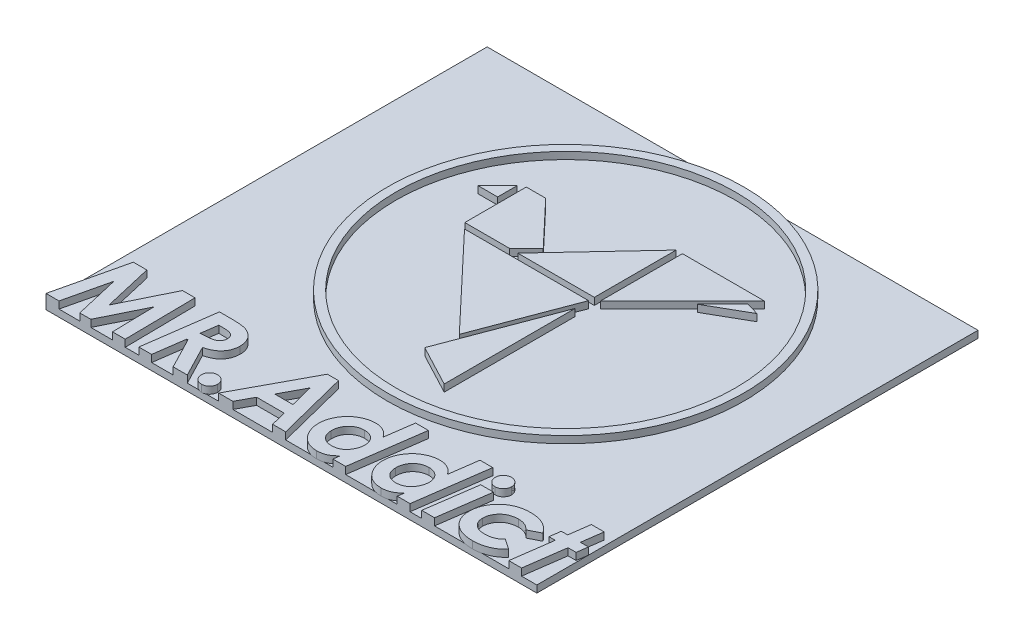
from build123d import *

# Parameters (mm, degrees)
SKETCH1_R              = 12.608404206
SKETCH1_R_2            = 12
BOSS_EXTRUDE3_DEPTH    = 0.5
BOSS_EXTRUDE3_2_DEPTH  = 0.5
BOSS_EXTRUDE3_3_DEPTH  = 0.5
BOSS_EXTRUDE3_4_DEPTH  = 0.5
BOSS_EXTRUDE3_5_DEPTH  = 0.5
BOSS_EXTRUDE3_6_DEPTH  = 0.5
BOSS_EXTRUDE3_7_DEPTH  = 0.5
BOSS_EXTRUDE3_8_DEPTH  = 0.5
BOSS_EXTRUDE4_DEPTH    = 0.5
BOSS_EXTRUDE4_2_DEPTH  = 0.5
BOSS_EXTRUDE4_3_DEPTH  = 0.5
BOSS_EXTRUDE4_4_DEPTH  = 0.5
BOSS_EXTRUDE4_5_DEPTH  = 0.5
BOSS_EXTRUDE4_6_DEPTH  = 0.5
BOSS_EXTRUDE4_7_DEPTH  = 0.5
BOSS_EXTRUDE4_8_DEPTH  = 0.5
BOSS_EXTRUDE4_9_DEPTH  = 0.5
BOSS_EXTRUDE4_10_DEPTH = 0.5
SKETCH4_W              = 34.698517628
SKETCH4_H              = 31.187303419
BOSS_EXTRUDE6_DEPTH    = 0.5


with BuildPart() as part:
    # Sketch1 → Boss-Extrude3 (new body)
    with BuildSketch(Plane(origin=(0, 0, 0), x_dir=(1, 0, 0), z_dir=(0, 1, 0))):
        with Locations((-2.743439084, 18.432560999)):
            Circle(SKETCH1_R)
        with Locations((-2.743439084, 18.432560999)):
            Circle(SKETCH1_R_2, mode=Mode.SUBTRACT)
    extrude(amount=BOSS_EXTRUDE3_DEPTH)



with BuildPart() as body_2:
    # Sketch1 → Boss-Extrude3 2 (new body)
    with BuildSketch(Plane(origin=(0, 0, 0), x_dir=(1, 0, 0), z_dir=(0, 1, 0))):
        Polygon((-4.195695336, 9.922143673), (-1.282837191, 8.382781522), (-1.282837191, 17.632650528), align=None)
    extrude(amount=BOSS_EXTRUDE3_2_DEPTH)


with BuildPart() as body_3:
    # Sketch1 → Boss-Extrude3 3 (new body)
    with BuildSketch(Plane(origin=(0, 0, 0), x_dir=(1, 0, 0), z_dir=(0, 1, 0))):
        Polygon((-3.788777798, 11.957432094), (-1.282837191, 18.590804289), (-10.053629316, 18.590804289), align=None)
    extrude(amount=BOSS_EXTRUDE3_3_DEPTH)


with BuildPart() as body_4:
    # Sketch1 → Boss-Extrude3 4 (new body)
    with BuildSketch(Plane(origin=(0, 0, 0), x_dir=(1, 0, 0), z_dir=(0, 1, 0))):
        Polygon((-1.282837191, 18.996177035), (-6.690878134, 18.996177035), (-1.282837191, 24.781951672), align=None)
    extrude(amount=BOSS_EXTRUDE3_4_DEPTH)


with BuildPart() as body_5:
    # Sketch1 → Boss-Extrude3 5 (new body)
    with BuildSketch(Plane(origin=(0, 0, 0), x_dir=(1, 0, 0), z_dir=(0, 1, 0))):
        Polygon((-0.840612378, 18.996177035), (4.945162259, 24.781951672), (-0.840612378, 24.781951672), align=None)
    extrude(amount=BOSS_EXTRUDE3_5_DEPTH)


with BuildPart() as body_6:
    # Sketch1 → Boss-Extrude3 6 (new body)
    with BuildSketch(Plane(origin=(0, 0, 0), x_dir=(1, 0, 0), z_dir=(0, 1, 0))):
        Polygon((-9.066559005, 23.343368384), (-10.439223382, 23.343368384), (-10.439223382, 18.996177035), (-7.289724235, 18.996177035), (-6.092032033, 20.193869237), align=None)
    extrude(amount=BOSS_EXTRUDE3_6_DEPTH)


with BuildPart() as body_7:
    # Sketch1 → Boss-Extrude3 7 (new body)
    with BuildSketch(Plane(origin=(0, 0, 0), x_dir=(1, 0, 0), z_dir=(0, 1, 0))):
        Polygon((-10.845948773, 21.723230048), (-12.227901314, 21.723230048), (-10.845948773, 23.105182589), align=None)
    extrude(amount=BOSS_EXTRUDE3_7_DEPTH)


with BuildPart() as body_8:
    # Sketch1 → Boss-Extrude3 8 (new body)
    with BuildSketch(Plane(origin=(0, 0, 0), x_dir=(1, 0, 0), z_dir=(0, 1, 0))):
        Polygon((5.461091208, 23.750093775), (4.576641582, 24.008058249), (2.789316296, 22.220732963), align=None)
    extrude(amount=BOSS_EXTRUDE3_8_DEPTH)


with BuildPart() as body_9:
    # Sketch3 → Boss-Extrude4 (new body)
    with BuildSketch(Plane(origin=(0, 0, 0), x_dir=(1, 0, 0), z_dir=(0, 1, 0))):
        Polygon((-19.727988587, 4.853661787), (-18.773461343, 4.853661787), (-17.963164869, 1.370088069), (-16.252427689, 4.853661787), (-15.367011022, 4.853661787), (-15.302908458, -0.146338213), (-16.200344356, -0.146338213), (-16.26444692, 2.844447043), (-17.732796279, -0.146338213), (-18.515047881, -0.146338213), (-19.245216151, 2.994687428), (-19.98339724, -0.146338213), (-20.902868394, -0.146338213), align=None)
    extrude(amount=BOSS_EXTRUDE4_DEPTH)


with BuildPart() as body_10:
    # Sketch3 → Boss-Extrude4 2 (new body)
    with BuildSketch(Plane(origin=(0, 0, 0), x_dir=(1, 0, 0), z_dir=(0, 1, 0))):
        with BuildLine():
            Line((-13.640248202, 4.853661787), (-12.771858779, 4.853661787))
            add(Edge.make_bspline(
                [(-12.771858779, 4.853661787), (-12.707414896, 4.853398433), (-12.583159342, 4.852890654), (-12.404475814, 4.845670045), (-12.240474733, 4.83477637), (-12.091351104, 4.820400008), (-11.956980424, 4.800453611), (-11.837642126, 4.776503965), (-11.732573968, 4.749832697), (-11.669564965, 4.725048015), (-11.640047881, 4.713437428)],
                knots=[0, 0, 0, 0, 0.00019332, 0.000372744, 0.000536376, 0.000686369, 0.000822071, 0.000943661, 0.001051537, 0.00114661, 0.00114661, 0.00114661, 0.00114661], degree=3))
            add(Edge.make_bspline(
                [(-11.640047881, 4.713437428), (-11.606815441, 4.698451185), (-11.54185128, 4.669155451), (-11.448761423, 4.619497385), (-11.361590017, 4.566002171), (-11.281781773, 4.506652864), (-11.207652489, 4.443948472), (-11.139661834, 4.377292593), (-11.078357274, 4.305662266), (-11.023095431, 4.230342276), (-10.97395684, 4.151430039), (-10.931776422, 4.068536415), (-10.895303745, 3.982363205), (-10.866821608, 3.891972693), (-10.843149528, 3.798449916), (-10.827839285, 3.701204808), (-10.817064659, 3.600565394), (-10.816179314, 3.532244386), (-10.815728971, 3.497491915)],
                knots=[0, 0, 0, 0, 0.00010934, 0.000213742, 0.000316303, 0.000415865, 0.000511794, 0.00060741, 0.000701165, 0.000794319, 0.000887431, 0.000979709, 0.001073089, 0.001167798, 0.001263753, 0.001362221, 0.001462881, 0.001567091, 0.001567091, 0.001567091, 0.001567091], degree=3))
            add(Edge.make_bspline(
                [(-10.815728971, 3.497491915), (-10.816788065, 3.454726608), (-10.818878889, 3.370300969), (-10.832540768, 3.245804007), (-10.85802187, 3.126336246), (-10.892337229, 3.011521354), (-10.934851204, 2.900615915), (-10.989678537, 2.795549768), (-11.053052116, 2.694492264), (-11.126242132, 2.598768331), (-11.208049597, 2.507499858), (-11.302508557, 2.426058097), (-11.404393409, 2.348965859), (-11.517889726, 2.281391837), (-11.639876079, 2.218621589), (-11.773134804, 2.16543882), (-11.915164843, 2.116359333), (-12.014753717, 2.091795733), (-12.065728971, 2.079222684)],
                knots=[0, 0, 0, 0, 0.000128303, 0.000253291, 0.000375083, 0.000494236, 0.000612531, 0.000730792, 0.000849172, 0.000969968, 0.001091917, 0.001216104, 0.001343508, 0.001474745, 0.001611815, 0.001754662, 0.001904795, 0.002062222, 0.002062222, 0.002062222, 0.002062222], degree=3))
            Line((-12.065728971, 2.079222684), (-10.911882817, -0.146338213))
            Line((-10.911882817, -0.146338213), (-11.914486984, -0.146338213))
            Line((-11.914486984, -0.146338213), (-13.044294676, 2.033148967))
            Line((-13.044294676, 2.033148967), (-13.129430894, 2.033148967))
            Line((-13.129430894, 2.033148967), (-13.435921279, -0.146338213))
            Line((-13.435921279, -0.146338213), (-14.341369997, -0.146338213))
            Line((-14.341369997, -0.146338213), (-13.640248202, 4.853661787))
        make_face()
        with BuildLine():
            add(Edge.make_bspline(
                [(-13.012243394, 2.8664823), (-12.947797574, 2.867080714), (-12.824528934, 2.868225329), (-12.648476948, 2.876186961), (-12.489718671, 2.888763447), (-12.348711964, 2.906736066), (-12.225085903, 2.927991172), (-12.119365657, 2.954526652), (-12.031066653, 2.986076856), (-11.958796191, 3.023492247), (-11.900252139, 3.067421566), (-11.849579747, 3.114301034), (-11.807385864, 3.166777409), (-11.772572129, 3.223969723), (-11.745721442, 3.285996516), (-11.726357946, 3.353278014), (-11.715651715, 3.425365608), (-11.714005862, 3.47508915), (-11.713164869, 3.500496723)],
                knots=[0, 0, 0, 0, 0.000193333, 0.000369797, 0.000528585, 0.000670957, 0.000796109, 0.000904699, 0.000997546, 0.00107685, 0.001147766, 0.001216498, 0.001283448, 0.001349066, 0.001416799, 0.001485589, 0.001558541, 0.001634768, 0.001634768, 0.001634768, 0.001634768], degree=3))
            add(Edge.make_bspline(
                [(-11.713164869, 3.500496723), (-11.714253501, 3.529305242), (-11.716365299, 3.585189819), (-11.73463149, 3.665679725), (-11.765866048, 3.738695003), (-11.809761962, 3.803537593), (-11.864541703, 3.860712578), (-11.931369985, 3.907802774), (-12.009483182, 3.944871818), (-12.082656615, 3.969362212), (-12.151919104, 3.983547676), (-12.21648509, 3.993078407), (-12.292929414, 4.002275223), (-12.381482017, 4.009075979), (-12.482036446, 4.013574551), (-12.594541507, 4.017945883), (-12.718770232, 4.019500353), (-12.805579623, 4.020044065), (-12.850985381, 4.020328454)],
                knots=[0, 0, 0, 0, 8.6347e-05, 0.000167502, 0.000246017, 0.000323245, 0.000401164, 0.000482319, 0.000566982, 0.000659786, 0.000713022, 0.000778892, 0.000855546, 0.000943965, 0.001045251, 0.001157502, 0.001281717, 0.001417938, 0.001417938, 0.001417938, 0.001417938], degree=3))
            Line((-12.850985381, 4.020328454), (-13.012243394, 2.8664823))
        make_face(mode=Mode.SUBTRACT)
    extrude(amount=BOSS_EXTRUDE4_2_DEPTH)


with BuildPart() as body_11:
    # Sketch3 → Boss-Extrude4 3 (new body)
    with BuildSketch(Plane(origin=(0, 0, 0), x_dir=(1, 0, 0), z_dir=(0, 1, 0))):
        with BuildLine():
            add(Edge.make_bspline(
                [(-9.85419051, 0.943405377), (-9.815873893, 0.941752785), (-9.740483823, 0.938501217), (-9.632664771, 0.904506838), (-9.532832832, 0.851585091), (-9.445478775, 0.777509713), (-9.370976591, 0.69001432), (-9.315663351, 0.590957802), (-9.283623084, 0.48126029), (-9.279423486, 0.405418903), (-9.277267433, 0.3664823)],
                knots=[0, 0, 0, 0, 0.000114621, 0.000225523, 0.000335759, 0.00045169, 0.000566852, 0.000678924, 0.000789541, 0.000906249, 0.000906249, 0.000906249, 0.000906249], degree=3))
            add(Edge.make_bspline(
                [(-9.277267433, 0.3664823), (-9.279482623, 0.328224394), (-9.283833908, 0.253074638), (-9.315609035, 0.143962394), (-9.371303597, 0.044912945), (-9.445056184, -0.043634807), (-9.53319565, -0.117265176), (-9.63216243, -0.172132272), (-9.740769279, -0.203899065), (-9.815928027, -0.20823394), (-9.85419051, -0.210440777)],
                knots=[0, 0, 0, 0, 0.000114713, 0.00022533, 0.000337402, 0.000453333, 0.000569264, 0.000679976, 0.000790593, 0.000905306, 0.000905306, 0.000905306, 0.000905306], degree=3))
            add(Edge.make_bspline(
                [(-9.85419051, -0.210440777), (-9.892778559, -0.20822082), (-9.968576908, -0.203860168), (-10.077969435, -0.17237102), (-10.177145532, -0.117207829), (-10.265312249, -0.043922324), (-10.338180625, 0.044978789), (-10.392603111, 0.144220036), (-10.424602744, 0.253048017), (-10.428917163, 0.328215414), (-10.431113587, 0.3664823)],
                knots=[0, 0, 0, 0, 0.00011571, 0.000227289, 0.000338001, 0.000453932, 0.000569225, 0.000680817, 0.000791434, 0.000906147, 0.000906147, 0.000906147, 0.000906147], degree=3))
            add(Edge.make_bspline(
                [(-10.431113587, 0.3664823), (-10.428976809, 0.405428084), (-10.424814756, 0.481287354), (-10.392548677, 0.590700613), (-10.338505736, 0.689943539), (-10.264888747, 0.777800967), (-10.177507864, 0.851525933), (-10.077467945, 0.904745444), (-9.968861027, 0.938464505), (-9.892832613, 0.941740383), (-9.85419051, 0.943405377)],
                knots=[0, 0, 0, 0, 0.000116707, 0.000227324, 0.000338916, 0.000453437, 0.000569368, 0.000679603, 0.000791465, 0.000907084, 0.000907084, 0.000907084, 0.000907084], degree=3))
        make_face()
    extrude(amount=BOSS_EXTRUDE4_3_DEPTH)


with BuildPart() as body_12:
    # Sketch3 → Boss-Extrude4 4 (new body)
    with BuildSketch(Plane(origin=(0, 0, 0), x_dir=(1, 0, 0), z_dir=(0, 1, 0))):
        Polygon((-6.013044676, 4.853661787), (-5.225785061, 4.853661787), (-3.956754612, -0.146338213), (-4.880232176, -0.146338213), (-5.156674484, 0.943405377), (-7.105793074, 0.943405377), (-7.690728971, -0.146338213), (-8.700344356, -0.146338213), align=None)
        Polygon((-5.37001583, 1.77673871), (-5.782676087, 3.404342877), (-6.657075125, 1.77673871), align=None, mode=Mode.SUBTRACT)
    extrude(amount=BOSS_EXTRUDE4_4_DEPTH)


with BuildPart() as body_13:
    # Sketch3 → Boss-Extrude4 5 (new body)
    with BuildSketch(Plane(origin=(0, 0, 0), x_dir=(1, 0, 0), z_dir=(0, 1, 0))):
        with BuildLine():
            Line((0.095729362, 4.981866915), (1.000176478, 4.981866915))
            Line((1.000176478, 4.981866915), (0.281025837, -0.146338213))
            Line((0.281025837, -0.146338213), (-0.623421279, -0.146338213))
            Line((-0.623421279, -0.146338213), (-0.56132192, 0.29236371))
            add(Edge.make_bspline(
                [(-0.56132192, 0.29236371), (-0.609890694, 0.248706586), (-0.70271783, 0.165266847), (-0.843859077, 0.054844927), (-0.981419262, -0.033036225), (-1.116339428, -0.100919661), (-1.252626632, -0.151584774), (-1.395046598, -0.184747329), (-1.544879471, -0.206746197), (-1.64764497, -0.209191542), (-1.700144035, -0.210440777)],
                knots=[0, 0, 0, 0, 0.000195889, 0.000374394, 0.000536944, 0.000684761, 0.000826727, 0.000972001, 0.001122715, 0.001280123, 0.001280123, 0.001280123, 0.001280123], degree=3))
            add(Edge.make_bspline(
                [(-1.700144035, -0.210440777), (-1.760333299, -0.209059046), (-1.878253226, -0.206352025), (-2.050095801, -0.180539046), (-2.212617537, -0.139574902), (-2.366152291, -0.082438106), (-2.509874979, -0.007822154), (-2.644404892, 0.082800026), (-2.767983003, 0.191245463), (-2.881359271, 0.313778616), (-2.982197579, 0.447550722), (-3.072336467, 0.586964241), (-3.147550516, 0.732640496), (-3.208678515, 0.883660949), (-3.257386259, 1.03963569), (-3.291124058, 1.201302844), (-3.31155927, 1.368226805), (-3.314328315, 1.481208275), (-3.315728971, 1.5383573)],
                knots=[0, 0, 0, 0, 0.000180466, 0.000353561, 0.000519966, 0.000682562, 0.000843833, 0.00100468, 0.001167968, 0.001335942, 0.001504616, 0.001669932, 0.001833442, 0.001995631, 0.002158153, 0.002322968, 0.002490436, 0.002661853, 0.002661853, 0.002661853, 0.002661853], degree=3))
            add(Edge.make_bspline(
                [(-3.315728971, 1.5383573), (-3.315045243, 1.582461147), (-3.313685099, 1.67019721), (-3.300055676, 1.801044131), (-3.278291355, 1.930271816), (-3.246735644, 2.057915578), (-3.207674998, 2.184006284), (-3.160998125, 2.308982805), (-3.102866502, 2.431038235), (-3.038648473, 2.551975059), (-2.965715515, 2.667973524), (-2.88745371, 2.779181628), (-2.802335308, 2.883183891), (-2.711096241, 2.980341217), (-2.614341623, 3.070902381), (-2.512219176, 3.155697938), (-2.402611609, 3.232104037), (-2.289077382, 3.303530788), (-2.170954276, 3.366096282), (-2.051101689, 3.421496679), (-1.929422012, 3.467377913), (-1.807199022, 3.505927969), (-1.683248511, 3.534919867), (-1.558124087, 3.555752315), (-1.43135785, 3.569615443), (-1.346280715, 3.570943063), (-1.30350942, 3.571610505)],
                knots=[0, 0, 0, 0, 0.000132272, 0.00026313, 0.000394202, 0.00052514, 0.00065725, 0.00079007, 0.000924945, 0.001062519, 0.001200646, 0.00133571, 0.001470242, 0.001603459, 0.00173526, 0.001867608, 0.002001276, 0.002135793, 0.002269772, 0.002401987, 0.002531644, 0.00265963, 0.002786204, 0.002913159, 0.003040031, 0.003168299, 0.003168299, 0.003168299, 0.003168299], degree=3))
            add(Edge.make_bspline(
                [(-1.30350942, 3.571610505), (-1.246954026, 3.56968427), (-1.135420146, 3.565885507), (-0.971965379, 3.535751235), (-0.815209838, 3.487908055), (-0.666806809, 3.419076429), (-0.526945155, 3.333109851), (-0.398990429, 3.228330198), (-0.284215191, 3.104778963), (-0.220286324, 3.011267699), (-0.187724163, 2.963637749)],
                knots=[0, 0, 0, 0, 0.000169567, 0.000334406, 0.000496928, 0.000660063, 0.000823779, 0.000988191, 0.001154749, 0.001327656, 0.001327656, 0.001327656, 0.001327656], degree=3))
            Line((-0.187724163, 2.963637749), (0.095729362, 4.981866915))
        make_face()
        with BuildLine():
            add(Edge.make_bspline(
                [(-1.508837945, 0.622892556), (-1.455293134, 0.624508077), (-1.350823833, 0.627660061), (-1.199749588, 0.655545669), (-1.058685452, 0.699400131), (-0.927897308, 0.762154222), (-0.806849315, 0.844282124), (-0.697513459, 0.947652662), (-0.598381831, 1.070955434), (-0.511460454, 1.211168939), (-0.437570036, 1.361376898), (-0.385591625, 1.517437633), (-0.351224105, 1.67473866), (-0.347722855, 1.78090346), (-0.345977369, 1.833830056)],
                knots=[0, 0, 0, 0, 0.00016051, 0.000313165, 0.000459196, 0.000602551, 0.000746733, 0.000896254, 0.001052212, 0.001220066, 0.001390294, 0.001553097, 0.001712601, 0.00187117, 0.00187117, 0.00187117, 0.00187117], degree=3))
            add(Edge.make_bspline(
                [(-0.345977369, 1.833830056), (-0.346736006, 1.866916349), (-0.348227816, 1.931978316), (-0.36024257, 2.026932441), (-0.380612271, 2.11661896), (-0.407312083, 2.201910149), (-0.443591408, 2.281540319), (-0.487047466, 2.357068483), (-0.539135062, 2.426666333), (-0.598419103, 2.491284314), (-0.664503335, 2.548493609), (-0.734479042, 2.600958457), (-0.811436005, 2.642106273), (-0.892063464, 2.678271164), (-0.978698825, 2.704546714), (-1.069636361, 2.725140008), (-1.166037997, 2.735790881), (-1.231705851, 2.737433256), (-1.265448522, 2.738277172)],
                knots=[0, 0, 0, 0, 9.924e-05, 0.000195148, 0.000286514, 0.000374888, 0.000462755, 0.000548478, 0.000635819, 0.000723005, 0.000811009, 0.000897756, 0.000984728, 0.00107219, 0.001162473, 0.001255794, 0.001351582, 0.001452823, 0.001452823, 0.001452823, 0.001452823], degree=3))
            add(Edge.make_bspline(
                [(-1.265448522, 2.738277172), (-1.304909231, 2.737458606), (-1.382501292, 2.735849049), (-1.49642698, 2.718832964), (-1.606085969, 2.693506284), (-1.710801782, 2.655603846), (-1.811622628, 2.608913239), (-1.906984661, 2.549827717), (-1.998800096, 2.481834639), (-2.084037359, 2.402658943), (-2.16306212, 2.31658242), (-2.231566505, 2.222859164), (-2.289214234, 2.122713483), (-2.335864493, 2.016416435), (-2.373809047, 1.904320261), (-2.39890968, 1.785961568), (-2.415938728, 1.661714877), (-2.417495915, 1.576812653), (-2.418293074, 1.533349287)],
                knots=[0, 0, 0, 0, 0.000118295, 0.000232605, 0.000344843, 0.000455405, 0.000566077, 0.000677561, 0.000791343, 0.000908308, 0.001026012, 0.001141405, 0.001255825, 0.001371963, 0.001489155, 0.001610179, 0.001734414, 0.001864719, 0.001864719, 0.001864719, 0.001864719], degree=3))
            add(Edge.make_bspline(
                [(-2.418293074, 1.533349287), (-2.41756299, 1.499923639), (-2.416134373, 1.434516872), (-2.403805264, 1.338974944), (-2.384049943, 1.248324163), (-2.355567676, 1.163024415), (-2.320959853, 1.081835699), (-2.276133319, 1.006933949), (-2.225036379, 0.935754886), (-2.165078103, 0.871312941), (-2.098861681, 0.813533926), (-2.028637666, 0.761742221), (-1.952987076, 0.718502592), (-1.872651164, 0.683528458), (-1.788094749, 0.656281619), (-1.69911022, 0.637609749), (-1.605685398, 0.624983441), (-1.54160039, 0.62359988), (-1.508837945, 0.622892556)],
                knots=[0, 0, 0, 0, 0.00010024, 0.000196149, 0.000288492, 0.000378128, 0.00046559, 0.000552683, 0.00063943, 0.000728031, 0.000816035, 0.000902782, 0.000989373, 0.001076834, 0.001165208, 0.00125538, 0.001349302, 0.00144754, 0.00144754, 0.00144754, 0.00144754], degree=3))
        make_face(mode=Mode.SUBTRACT)
    extrude(amount=BOSS_EXTRUDE4_5_DEPTH)


with BuildPart() as body_14:
    # Sketch3 → Boss-Extrude4 6 (new body)
    with BuildSketch(Plane(origin=(0, 0, 0), x_dir=(1, 0, 0), z_dir=(0, 1, 0))):
        with BuildLine():
            Line((4.647011413, 4.981866915), (5.551458529, 4.981866915))
            Line((5.551458529, 4.981866915), (4.832307888, -0.146338213))
            Line((4.832307888, -0.146338213), (3.927860772, -0.146338213))
            Line((3.927860772, -0.146338213), (3.989960131, 0.29236371))
            add(Edge.make_bspline(
                [(3.989960131, 0.29236371), (3.941391358, 0.248706586), (3.848564221, 0.165266847), (3.707422975, 0.054844927), (3.569862789, -0.033036225), (3.434942624, -0.100919661), (3.298655419, -0.151584774), (3.156235453, -0.184747329), (3.00640258, -0.206746197), (2.903637081, -0.209191542), (2.851138016, -0.210440777)],
                knots=[0, 0, 0, 0, 0.000195889, 0.000374394, 0.000536944, 0.000684761, 0.000826727, 0.000972001, 0.001122715, 0.001280123, 0.001280123, 0.001280123, 0.001280123], degree=3))
            add(Edge.make_bspline(
                [(2.851138016, -0.210440777), (2.790948752, -0.209059046), (2.673028826, -0.206352025), (2.50118625, -0.180539046), (2.338664514, -0.139574902), (2.18512976, -0.082438106), (2.041407072, -0.007822154), (1.906877159, 0.082800026), (1.783299048, 0.191245463), (1.66992278, 0.313778616), (1.569084472, 0.447550722), (1.478945584, 0.586964241), (1.403731535, 0.732640496), (1.342603536, 0.883660949), (1.293895792, 1.03963569), (1.260157993, 1.201302844), (1.239722782, 1.368226805), (1.236953737, 1.481208275), (1.23555308, 1.5383573)],
                knots=[0, 0, 0, 0, 0.000180466, 0.000353561, 0.000519966, 0.000682562, 0.000843833, 0.00100468, 0.001167968, 0.001335942, 0.001504616, 0.001669932, 0.001833442, 0.001995631, 0.002158153, 0.002322968, 0.002490436, 0.002661853, 0.002661853, 0.002661853, 0.002661853], degree=3))
            add(Edge.make_bspline(
                [(1.23555308, 1.5383573), (1.236236808, 1.582461147), (1.237596952, 1.67019721), (1.251226375, 1.801044131), (1.272990696, 1.930271816), (1.304546407, 2.057915578), (1.343607053, 2.184006284), (1.390283926, 2.308982805), (1.44841555, 2.431038235), (1.512633578, 2.551975059), (1.585566536, 2.667973524), (1.663828341, 2.779181628), (1.748946743, 2.883183891), (1.84018581, 2.980341217), (1.936940429, 3.070902381), (2.039062875, 3.155697938), (2.148670442, 3.232104037), (2.262204669, 3.303530788), (2.380327776, 3.366096282), (2.500180362, 3.421496679), (2.621860039, 3.467377913), (2.744083029, 3.505927969), (2.868033541, 3.534919867), (2.993157965, 3.555752315), (3.119924201, 3.569615443), (3.205001337, 3.570943063), (3.247772631, 3.571610505)],
                knots=[0, 0, 0, 0, 0.000132272, 0.00026313, 0.000394202, 0.00052514, 0.00065725, 0.00079007, 0.000924945, 0.001062519, 0.001200646, 0.00133571, 0.001470242, 0.001603459, 0.00173526, 0.001867608, 0.002001276, 0.002135793, 0.002269772, 0.002401987, 0.002531644, 0.00265963, 0.002786204, 0.002913159, 0.003040031, 0.003168299, 0.003168299, 0.003168299, 0.003168299], degree=3))
            add(Edge.make_bspline(
                [(3.247772631, 3.571610505), (3.304328025, 3.56968427), (3.415861906, 3.565885507), (3.579316673, 3.535751235), (3.736072213, 3.487908055), (3.884475242, 3.419076429), (4.024336897, 3.333109851), (4.152291623, 3.228330198), (4.267066861, 3.104778963), (4.330995727, 3.011267699), (4.363557888, 2.963637749)],
                knots=[0, 0, 0, 0, 0.000169567, 0.000334406, 0.000496928, 0.000660063, 0.000823779, 0.000988191, 0.001154749, 0.001327656, 0.001327656, 0.001327656, 0.001327656], degree=3))
            Line((4.363557888, 2.963637749), (4.647011413, 4.981866915))
        make_face()
        with BuildLine():
            add(Edge.make_bspline(
                [(3.042444106, 0.622892556), (3.095988917, 0.624508077), (3.200458218, 0.627660061), (3.351532464, 0.655545669), (3.492596599, 0.699400131), (3.623384743, 0.762154222), (3.744432736, 0.844282124), (3.853768592, 0.947652662), (3.95290022, 1.070955434), (4.039821597, 1.211168939), (4.113712016, 1.361376898), (4.165690427, 1.517437633), (4.200057947, 1.67473866), (4.203559196, 1.78090346), (4.205304683, 1.833830056)],
                knots=[0, 0, 0, 0, 0.00016051, 0.000313165, 0.000459196, 0.000602551, 0.000746733, 0.000896254, 0.001052212, 0.001220066, 0.001390294, 0.001553097, 0.001712601, 0.00187117, 0.00187117, 0.00187117, 0.00187117], degree=3))
            add(Edge.make_bspline(
                [(4.205304683, 1.833830056), (4.204546045, 1.866916349), (4.203054235, 1.931978316), (4.191039482, 2.026932441), (4.170669781, 2.11661896), (4.143969968, 2.201910149), (4.107690643, 2.281540319), (4.064234586, 2.357068483), (4.012146989, 2.426666333), (3.952862949, 2.491284314), (3.886778716, 2.548493609), (3.81680301, 2.600958457), (3.739846046, 2.642106273), (3.659218587, 2.678271164), (3.572583226, 2.704546714), (3.48164569, 2.725140008), (3.385244054, 2.735790881), (3.319576201, 2.737433256), (3.285833529, 2.738277172)],
                knots=[0, 0, 0, 0, 9.924e-05, 0.000195148, 0.000286514, 0.000374888, 0.000462755, 0.000548478, 0.000635819, 0.000723005, 0.000811009, 0.000897756, 0.000984728, 0.00107219, 0.001162473, 0.001255794, 0.001351582, 0.001452823, 0.001452823, 0.001452823, 0.001452823], degree=3))
            add(Edge.make_bspline(
                [(3.285833529, 2.738277172), (3.24637282, 2.737458606), (3.168780759, 2.735849049), (3.054855071, 2.718832964), (2.945196082, 2.693506284), (2.840480269, 2.655603846), (2.739659423, 2.608913239), (2.64429739, 2.549827717), (2.552481955, 2.481834639), (2.467244692, 2.402658943), (2.388219931, 2.31658242), (2.319715547, 2.222859164), (2.262067818, 2.122713483), (2.215417559, 2.016416435), (2.177473004, 1.904320261), (2.152372371, 1.785961568), (2.135343323, 1.661714877), (2.133786137, 1.576812653), (2.132988978, 1.533349287)],
                knots=[0, 0, 0, 0, 0.000118295, 0.000232605, 0.000344843, 0.000455405, 0.000566077, 0.000677561, 0.000791343, 0.000908308, 0.001026012, 0.001141405, 0.001255825, 0.001371963, 0.001489155, 0.001610179, 0.001734414, 0.001864719, 0.001864719, 0.001864719, 0.001864719], degree=3))
            add(Edge.make_bspline(
                [(2.132988978, 1.533349287), (2.133719062, 1.499923639), (2.135147678, 1.434516872), (2.147476788, 1.338974944), (2.167232108, 1.248324163), (2.195714375, 1.163024415), (2.230322198, 1.081835699), (2.275148732, 1.006933949), (2.326245673, 0.935754886), (2.386203949, 0.871312941), (2.45242037, 0.813533926), (2.522644386, 0.761742221), (2.598294976, 0.718502592), (2.678630888, 0.683528458), (2.763187302, 0.656281619), (2.852171832, 0.637609749), (2.945596653, 0.624983441), (3.009681661, 0.62359988), (3.042444106, 0.622892556)],
                knots=[0, 0, 0, 0, 0.00010024, 0.000196149, 0.000288492, 0.000378128, 0.00046559, 0.000552683, 0.00063943, 0.000728031, 0.000816035, 0.000902782, 0.000989373, 0.001076834, 0.001165208, 0.00125538, 0.001349302, 0.00144754, 0.00144754, 0.00144754, 0.00144754], degree=3))
        make_face(mode=Mode.SUBTRACT)
    extrude(amount=BOSS_EXTRUDE4_6_DEPTH)


with BuildPart() as body_15:
    # Sketch3 → Boss-Extrude4 7 (new body)
    with BuildSketch(Plane(origin=(0, 0, 0), x_dir=(1, 0, 0), z_dir=(0, 1, 0))):
        with BuildLine():
            add(Edge.make_bspline(
                [(6.812476157, 5.045969479), (6.85072542, 5.043739081), (6.9258582, 5.039357924), (7.034811147, 5.007883605), (7.133168477, 4.951587465), (7.221696245, 4.87826649), (7.295017219, 4.789738723), (7.351313359, 4.691381393), (7.382787679, 4.582428445), (7.387168836, 4.507295665), (7.389399234, 4.469046402)],
                knots=[0, 0, 0, 0, 0.000114713, 0.00022533, 0.000336526, 0.000452457, 0.000568388, 0.000679584, 0.000790201, 0.000904914, 0.000904914, 0.000904914, 0.000904914], degree=3))
            add(Edge.make_bspline(
                [(7.389399234, 4.469046402), (7.387184043, 4.430788497), (7.382832759, 4.355638741), (7.351057632, 4.246526496), (7.29536307, 4.147477048), (7.221610483, 4.058929296), (7.133471016, 3.985298927), (7.034504237, 3.930431831), (6.925897388, 3.898665037), (6.85073864, 3.894330162), (6.812476157, 3.892123326)],
                knots=[0, 0, 0, 0, 0.000114713, 0.00022533, 0.000337402, 0.000453333, 0.000569264, 0.000679976, 0.000790593, 0.000905306, 0.000905306, 0.000905306, 0.000905306], degree=3))
            add(Edge.make_bspline(
                [(6.812476157, 3.892123326), (6.774205232, 3.894315068), (6.6990299, 3.898620294), (6.590259969, 3.93068719), (6.490607539, 3.98495338), (6.402443661, 4.059013907), (6.328383134, 4.147177785), (6.274116944, 4.246830214), (6.242050048, 4.355600146), (6.237744823, 4.430775477), (6.23555308, 4.469046402)],
                knots=[0, 0, 0, 0, 0.000114713, 0.00022533, 0.000336922, 0.000452853, 0.000568784, 0.000680376, 0.000790993, 0.000905706, 0.000905706, 0.000905706, 0.000905706], degree=3))
            add(Edge.make_bspline(
                [(6.23555308, 4.469046402), (6.237759917, 4.507308885), (6.242094792, 4.582467633), (6.273861585, 4.691074482), (6.328728682, 4.790041262), (6.40235905, 4.878180728), (6.490906802, 4.951933315), (6.589956251, 5.007627877), (6.699068495, 5.039403004), (6.774218252, 5.043754289), (6.812476157, 5.045969479)],
                knots=[0, 0, 0, 0, 0.000114713, 0.00022533, 0.000336042, 0.000451973, 0.000567904, 0.000679976, 0.000790593, 0.000905306, 0.000905306, 0.000905306, 0.000905306], degree=3))
        make_face()
    extrude(amount=BOSS_EXTRUDE4_7_DEPTH)


with BuildPart() as body_16:
    # Sketch3 → Boss-Extrude4 8 (new body)
    with BuildSketch(Plane(origin=(0, 0, 0), x_dir=(1, 0, 0), z_dir=(0, 1, 0))):
        Polygon((6.177460131, 3.507507941), (7.082908849, 3.507507941), (6.564078721, -0.146338213), (5.658630003, -0.146338213), align=None)
    extrude(amount=BOSS_EXTRUDE4_8_DEPTH)


with BuildPart() as body_17:
    # Sketch3 → Boss-Extrude4 9 (new body)
    with BuildSketch(Plane(origin=(0, 0, 0), x_dir=(1, 0, 0), z_dir=(0, 1, 0))):
        with BuildLine():
            Line((11.331706926, 2.742283582), (10.53242808, 2.338637749))
            add(Edge.make_bspline(
                [(10.53242808, 2.338637749), (10.503808542, 2.370782238), (10.447271114, 2.434283148), (10.350072319, 2.515363711), (10.246148672, 2.584046024), (10.134980624, 2.640606349), (10.016426039, 2.684922349), (9.890291658, 2.715436934), (9.757486021, 2.735317784), (9.666449894, 2.737276883), (9.619968144, 2.738277172)],
                knots=[0, 0, 0, 0, 0.00012897, 0.000254778, 0.000378397, 0.000502029, 0.000628168, 0.000757161, 0.000890735, 0.001030087, 0.001030087, 0.001030087, 0.001030087], degree=3))
            add(Edge.make_bspline(
                [(9.619968144, 2.738277172), (9.557433344, 2.736268439), (9.435387122, 2.732348091), (9.257664129, 2.704242153), (9.091073072, 2.656065462), (8.936562916, 2.588535434), (8.793889314, 2.505034163), (8.668050148, 2.400954673), (8.555151803, 2.281994528), (8.460480044, 2.146474763), (8.383325632, 2.001218357), (8.32759254, 1.84933742), (8.293202369, 1.693142876), (8.288957135, 1.587271358), (8.286835131, 1.53435089)],
                knots=[0, 0, 0, 0, 0.000187567, 0.000366066, 0.000538182, 0.000706394, 0.000870782, 0.001032376, 0.001194639, 0.001361375, 0.0015267, 0.001686721, 0.001845449, 0.002004085, 0.002004085, 0.002004085, 0.002004085], degree=3))
            add(Edge.make_bspline(
                [(8.286835131, 1.53435089), (8.287512711, 1.500921579), (8.288846179, 1.435133096), (8.302046705, 1.33912424), (8.323986974, 1.248072569), (8.355413557, 1.162639941), (8.394449591, 1.081753348), (8.442905124, 1.006122714), (8.500496013, 0.936043834), (8.565337181, 0.870578889), (8.638956636, 0.812615675), (8.719057632, 0.761429984), (8.805720045, 0.718258548), (8.898631112, 0.68299716), (8.998284008, 0.655966426), (9.104618989, 0.637611741), (9.21702313, 0.62496895), (9.294076763, 0.623595457), (9.333509811, 0.622892556)],
                knots=[0, 0, 0, 0, 0.00010024, 0.000197272, 0.00029007, 0.000380692, 0.000469834, 0.000559022, 0.000649438, 0.00074151, 0.000834895, 0.000929921, 0.001026226, 0.001124816, 0.001227597, 0.001335459, 0.00144828, 0.001566537, 0.001566537, 0.001566537, 0.001566537], degree=3))
            add(Edge.make_bspline(
                [(9.333509811, 0.622892556), (9.388317484, 0.624330193), (9.494602589, 0.627118114), (9.649332041, 0.646056604), (9.794462705, 0.678913544), (9.929675288, 0.726031438), (10.055443899, 0.785580458), (10.171475357, 0.85795112), (10.277746628, 0.944332491), (10.339249725, 1.011701298), (10.370168465, 1.045568838)],
                knots=[0, 0, 0, 0, 0.000164412, 0.000318835, 0.000466804, 0.000609981, 0.000747522, 0.000883419, 0.00101936, 0.001156788, 0.001156788, 0.001156788, 0.001156788], degree=3))
            Line((10.370168465, 1.045568838), (11.112355965, 0.548773967))
            add(Edge.make_bspline(
                [(11.112355965, 0.548773967), (11.05857662, 0.49130856), (10.950723888, 0.376063551), (10.763964521, 0.22706199), (10.559812459, 0.095947059), (10.336975626, -0.013876503), (10.098522755, -0.102271132), (9.845357515, -0.165486791), (9.578679727, -0.202775291), (9.396395783, -0.207852339), (9.303461734, -0.210440777)],
                knots=[0, 0, 0, 0, 0.000235853, 0.000472997, 0.000714441, 0.000962596, 0.00121675, 0.001475951, 0.00174395, 0.0020227, 0.0020227, 0.0020227, 0.0020227], degree=3))
            add(Edge.make_bspline(
                [(9.303461734, -0.210440777), (9.231279478, -0.209282316), (9.090565788, -0.207023987), (8.885395598, -0.18401439), (8.691744835, -0.149230002), (8.51049716, -0.097109338), (8.339672665, -0.033792551), (8.181350194, 0.046586891), (8.034904167, 0.141609159), (7.900793721, 0.249492889), (7.780362453, 0.369564391), (7.676102262, 0.50028099), (7.586728771, 0.639583801), (7.514319034, 0.788901814), (7.458397114, 0.947593993), (7.418240442, 1.115388013), (7.393771687, 1.292241133), (7.390876784, 1.413411402), (7.389399234, 1.475256338)],
                knots=[0, 0, 0, 0, 0.00021646, 0.000421971, 0.000618615, 0.000806, 0.000987002, 0.001164385, 0.001337465, 0.001509846, 0.001679823, 0.001846571, 0.002010504, 0.002175352, 0.002343251, 0.002514276, 0.00269219, 0.002877659, 0.002877659, 0.002877659, 0.002877659], degree=3))
            add(Edge.make_bspline(
                [(7.389399234, 1.475256338), (7.391236091, 1.546485048), (7.394857679, 1.686921157), (7.426198806, 1.893180601), (7.474779473, 2.091733237), (7.544433321, 2.28210838), (7.63406072, 2.464437285), (7.744119313, 2.638195062), (7.873045435, 2.804402465), (8.020757451, 2.960517287), (8.18322503, 3.104187428), (8.360232921, 3.229064093), (8.547749096, 3.335922957), (8.747464246, 3.422122574), (8.958131083, 3.48954146), (9.180140976, 3.53748179), (9.413914313, 3.565641024), (9.573483227, 3.569591685), (9.655024234, 3.571610505)],
                knots=[0, 0, 0, 0, 0.000213576, 0.000421092, 0.00062442, 0.000825943, 0.001027964, 0.001232767, 0.001441929, 0.001658037, 0.001876634, 0.002091456, 0.002306754, 0.00252297, 0.002742799, 0.002969314, 0.003203372, 0.003447968, 0.003447968, 0.003447968, 0.003447968], degree=3))
            add(Edge.make_bspline(
                [(9.655024234, 3.571610505), (9.701119842, 3.57114783), (9.792088815, 3.570234749), (9.926089266, 3.55958441), (10.055611706, 3.544225941), (10.180510359, 3.520552149), (10.301037098, 3.492114179), (10.417442342, 3.456635401), (10.529392554, 3.414971087), (10.636628323, 3.365675257), (10.739175628, 3.310224605), (10.83771486, 3.249422207), (10.931209238, 3.180784107), (11.020198589, 3.105461574), (11.105513769, 3.024517342), (11.185933002, 2.936678745), (11.262239302, 2.842927771), (11.308439646, 2.775993048), (11.331706926, 2.742283582)],
                knots=[0, 0, 0, 0, 0.000138254, 0.000272842, 0.000403039, 0.000529356, 0.000653982, 0.000774383, 0.00089419, 0.001012065, 0.001128134, 0.001243753, 0.001359146, 0.00147572, 0.001593322, 0.001711702, 0.001832776, 0.001955614, 0.001955614, 0.001955614, 0.001955614], degree=3))
        make_face()
    extrude(amount=BOSS_EXTRUDE4_9_DEPTH)


with BuildPart() as body_18:
    # Sketch3 → Boss-Extrude4 10 (new body)
    with BuildSketch(Plane(origin=(0, 0, 0), x_dir=(1, 0, 0), z_dir=(0, 1, 0))):
        Polygon((12.523613978, 4.981866915), (13.428061093, 4.981866915), (13.22373417, 3.507507941), (13.795649234, 3.507507941), (13.687476157, 2.738277172), (13.116562696, 2.738277172), (12.716923272, -0.146338213), (11.812476157, -0.146338213), (12.21211558, 2.738277172), (11.769407247, 2.738277172), (11.873573913, 3.507507941), (12.319287055, 3.507507941), align=None)
    extrude(amount=BOSS_EXTRUDE4_10_DEPTH)


with BuildPart() as part_1:
    add(part.part)

    add(body_2.part)  # Boss-Extrude6 merges body 2

    add(body_3.part)  # Boss-Extrude6 merges body 3

    add(body_4.part)  # Boss-Extrude6 merges body 4

    add(body_5.part)  # Boss-Extrude6 merges body 5

    add(body_6.part)  # Boss-Extrude6 merges body 6

    add(body_7.part)  # Boss-Extrude6 merges body 7

    add(body_8.part)  # Boss-Extrude6 merges body 8

    add(body_9.part)  # Boss-Extrude6 merges body 9

    add(body_10.part)  # Boss-Extrude6 merges body 10

    add(body_11.part)  # Boss-Extrude6 merges body 11

    add(body_12.part)  # Boss-Extrude6 merges body 12

    add(body_13.part)  # Boss-Extrude6 merges body 13

    add(body_14.part)  # Boss-Extrude6 merges body 14

    add(body_15.part)  # Boss-Extrude6 merges body 15

    add(body_16.part)  # Boss-Extrude6 merges body 16

    add(body_17.part)  # Boss-Extrude6 merges body 17

    add(body_18.part)  # Boss-Extrude6 merges body 18
    # Sketch4 → Boss-Extrude6 (add)
    with BuildSketch(Plane(origin=(0, 0, 0), x_dir=(-1, 0, 0), z_dir=(0, -1, 0))):
        with Locations((3.55360958, 15.447313497)):
            Rectangle(SKETCH4_W, SKETCH4_H)
    extrude(amount=BOSS_EXTRUDE6_DEPTH)


solid = part_1.part
